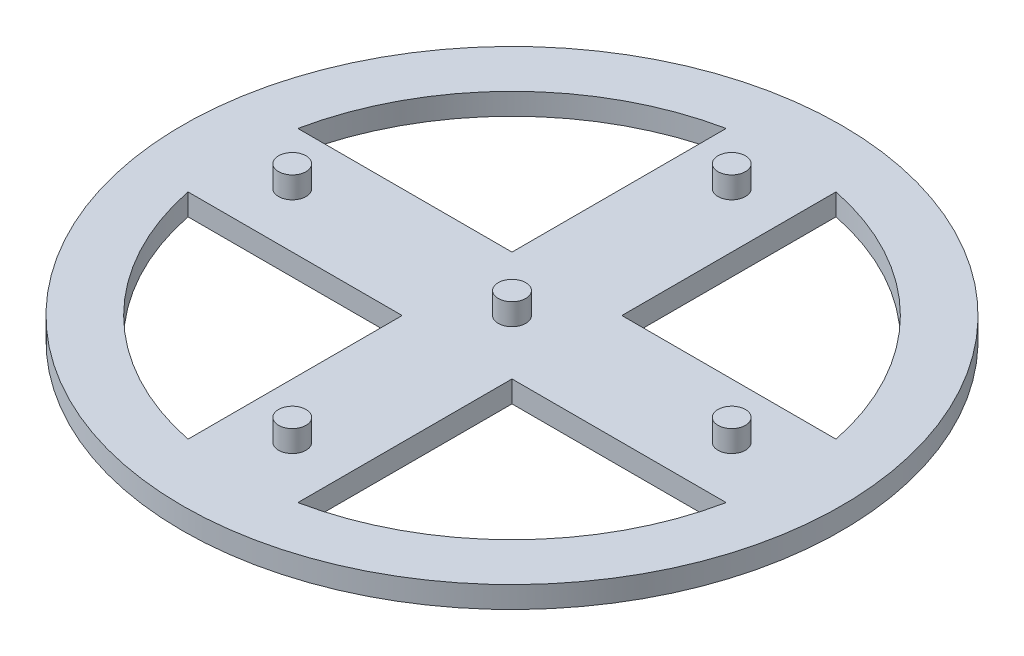
from build123d import *

# Parameters (mm, degrees)
SKETCH1_R           = 38.1
BOSS_EXTRUDE1_DEPTH = 2.5
SKETCH2_R           = 1.5875
BOSS_EXTRUDE2_DEPTH = 2.5


with BuildPart() as part:
    # Sketch1 → Boss-Extrude1 (new body)
    with BuildSketch(Plane(origin=(0, 0, 0), x_dir=(1, 0, 0), z_dir=(0, 1, 0))):
        Circle(SKETCH1_R)
        with BuildLine():
            ThreePointArc((6.35, -31.108519733), (22.450640303, -22.450640303), (31.108519733, -6.35))
            Line((31.108519733, -6.35), (6.35, -6.35))
            Line((6.35, -6.35), (6.35, -31.108519733))
        make_face(mode=Mode.SUBTRACT)
        with BuildLine():
            ThreePointArc((-31.108519733, -6.35), (-22.450640303, -22.450640303), (-6.35, -31.108519733))
            Line((-6.35, -31.108519733), (-6.35, -6.35))
            Line((-6.35, -6.35), (-31.108519733, -6.35))
        make_face(mode=Mode.SUBTRACT)
        with BuildLine():
            ThreePointArc((-6.35, 31.108519733), (-22.450640303, 22.450640303), (-31.108519733, 6.35))
            Line((-31.108519733, 6.35), (-6.35, 6.35))
            Line((-6.35, 6.35), (-6.35, 31.108519733))
        make_face(mode=Mode.SUBTRACT)
        with BuildLine():
            ThreePointArc((31.108519733, 6.35), (22.450640303, 22.450640303), (6.35, 31.108519733))
            Line((6.35, 31.108519733), (6.35, 6.35))
            Line((6.35, 6.35), (31.108519733, 6.35))
        make_face(mode=Mode.SUBTRACT)
    extrude(amount=BOSS_EXTRUDE1_DEPTH)

    # Sketch2 → Boss-Extrude2 (add)
    with BuildSketch(Plane(origin=(0, 2.5, 0), x_dir=(1, 0, 0), z_dir=(0, 1, 0))):
        Circle(SKETCH2_R)
        with Locations((-25.4, 0)):
            Circle(SKETCH2_R)
        with Locations((0, 25.4)):
            Circle(SKETCH2_R)
        with Locations((25.4, 0)):
            Circle(SKETCH2_R)
        with Locations((0, -25.4)):
            Circle(SKETCH2_R)
    extrude(amount=BOSS_EXTRUDE2_DEPTH)


solid = part.part
